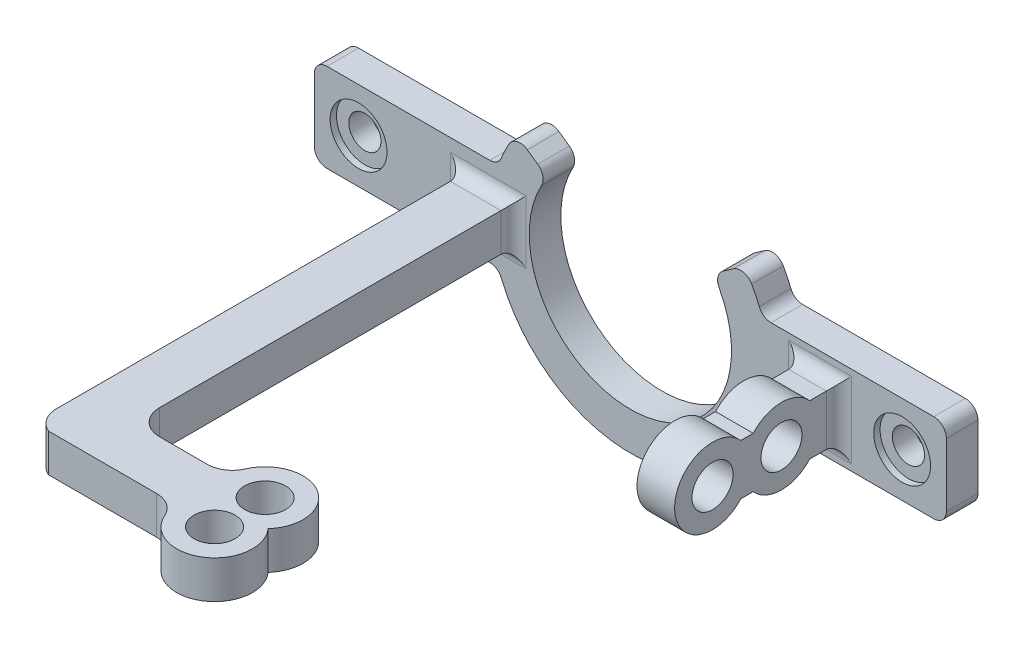
from build123d import *

# Parameters (mm, degrees)
SKETCH1_R                = 2.55
BOSS_EXTRUDE1_DEPTH      = 5
SKETCH4_R                = 4.5
CUT_EXTRUDE2_DEPTH       = 1
SKETCH6_W                = 5.947651005
SKETCH6_H                = 20
BOSS_EXTRUDE2_DEPTH      = 4
BOSS_EXTRUDE2_DEPTH_BACK = 4
SKETCH11_R               = 4.5
CUT_EXTRUDE3_DEPTH       = 0.5
SKETCH16_R               = 3.25
BOSS_EXTRUDE3_DEPTH      = 3
BOSS_EXTRUDE3_DEPTH_BACK = 3
FILLET3_R                = 2
BOSS_EXTRUDE4_DEPTH      = 5.947651
CUT_EXTRUDE5_REACH       = 85
SKETCH18_R               = 3.25


with BuildPart() as part:
    # Sketch1 → Boss-Extrude1 (new body)
    with BuildSketch(Plane.XY):
        with BuildLine():
            Line((100, 25), (100, 20))
            ThreePointArc((100, 20), (99.414213562, 18.585786438), (98, 18))
            Line((98, 18), (72.248595461, 18))
            ThreePointArc((72.248595461, 18), (71.130561473, 17.658312395), (70.39454584, 16.75))
            ThreePointArc((70.39454584, 16.75), (50, 3), (29.60545416, 16.75))
            ThreePointArc((29.60545416, 16.75), (28.869438527, 17.658312395), (27.751404539, 18))
            Line((27.751404539, 18), (2, 18))
            ThreePointArc((2, 18), (0.585786438, 18.585786438), (0, 20))
            Line((0, 20), (0, 25))
            Line((0, 25), (0, 30))
            ThreePointArc((0, 30), (0.585786438, 31.414213562), (2, 32))
            Line((2, 32), (21.056240945, 32))
            Line((21.056240945, 32), (27.751404539, 32))
            ThreePointArc((27.751404539, 32), (28.869438527, 32.341687605), (29.60545416, 33.25))
            ThreePointArc((29.60545416, 33.25), (30.166752838, 34.520625347), (30.807119991, 35.753295167))
            ThreePointArc((30.807119991, 35.753295167), (32.106461975, 36.725482012), (33.699080137, 36.414026968))
            Line((33.699080137, 36.414026968), (35.34656276, 35.260447216))
            ThreePointArc((35.34656276, 35.260447216), (36.146649881, 34.078494315), (35.955031011, 32.664127224))
            ThreePointArc((35.955031011, 32.664127224), (50, 9), (64.044968989, 32.664127224))
            ThreePointArc((64.044968989, 32.664127224), (63.853350119, 34.078494315), (64.65343724, 35.260447216))
            Line((64.65343724, 35.260447216), (66.300919863, 36.414026968))
            ThreePointArc((66.300919863, 36.414026968), (67.893538025, 36.725482012), (69.192880009, 35.753295167))
            ThreePointArc((69.192880009, 35.753295167), (69.833247162, 34.520625347), (70.39454584, 33.25))
            ThreePointArc((70.39454584, 33.25), (71.130561473, 32.341687605), (72.248595461, 32))
            Line((72.248595461, 32), (78.943759055, 32))
            Line((78.943759055, 32), (98, 32))
            ThreePointArc((98, 32), (99.414213562, 31.414213562), (100, 30))
            Line((100, 30), (100, 25))
        make_face()
        with Locations((93, 25)):
            Circle(SKETCH1_R, mode=Mode.SUBTRACT)
        with Locations((7, 25)):
            Circle(SKETCH1_R, mode=Mode.SUBTRACT)
    extrude(amount=BOSS_EXTRUDE1_DEPTH)

    # Sketch4 → Cut-Extrude2 (cut)
    with BuildSketch(Plane.XY.offset(5)):
        with Locations((93, 25)):
            Circle(SKETCH4_R)
        with Locations((7, 25)):
            Circle(SKETCH4_R)
    extrude(amount=-CUT_EXTRUDE2_DEPTH, mode=Mode.SUBTRACT)

    # Sketch6 → Boss-Extrude2 (add, two sides)
    with BuildSketch(Plane(origin=(0, 25, 0), x_dir=(-1, 0, 0), z_dir=(0, -1, 0))) as boss_extrude2_sk:
        with Locations((-80.026174497, -15)):
            Rectangle(SKETCH6_W, SKETCH6_H)
    extrude(amount=BOSS_EXTRUDE2_DEPTH)
    extrude(boss_extrude2_sk.sketch, amount=-BOSS_EXTRUDE2_DEPTH_BACK)

    # Sketch11 → Cut-Extrude3 (cut)
    with BuildSketch(Plane(origin=(0, 0, 0), x_dir=(-1, 0, 0), z_dir=(0, 0, -1))):
        with Locations((-93, 25)):
            Circle(SKETCH11_R)
        with Locations((-7, 25)):
            Circle(SKETCH11_R)
    extrude(amount=-CUT_EXTRUDE3_DEPTH, mode=Mode.SUBTRACT)

    # Sketch16 → Boss-Extrude3 (add, two sides)
    with BuildSketch(Plane(origin=(0, 25, 0), x_dir=(-1, 0, 0), z_dir=(0, -1, 0))) as boss_extrude3_sk:
        with BuildLine():
            Line((-31.525983958, -5), (-31.525983958, -48.851508305))
            Line((-31.525983958, -48.851508305), (-31.525983958, -61))
            ThreePointArc((-31.525983958, -61), (-32.697556833, -63.828427125), (-35.525983958, -65))
            Line((-35.525983958, -65), (-43.054928699, -65))
            ThreePointArc((-43.054928699, -65), (-45.245818929, -64.346640106), (-46.720989255, -62.6))
            ThreePointArc((-46.720989255, -62.6), (-55.461014998, -59.950609847), (-56.692216044, -69))
            ThreePointArc((-56.692216044, -69), (-55.461014998, -78.049390153), (-46.720989255, -75.4))
            ThreePointArc((-46.720989255, -75.4), (-45.245818929, -73.653359894), (-43.054928699, -73))
            Line((-43.054928699, -73), (-25.956550891, -73))
            ThreePointArc((-25.956550891, -73), (-24.188489968, -71.525548017), (-23.525983958, -69.320750097))
            Line((-23.525983958, -69.320750097), (-23.525983958, -5))
            Line((-23.525983958, -5), (-31.525983958, -5))
        make_face()
        with Locations((-52.220080089, -73)):
            Circle(SKETCH16_R, mode=Mode.SUBTRACT)
        with Locations((-52.220080089, -65)):
            Circle(SKETCH16_R, mode=Mode.SUBTRACT)
    extrude(amount=BOSS_EXTRUDE3_DEPTH)
    extrude(boss_extrude3_sk.sketch, amount=-BOSS_EXTRUDE3_DEPTH_BACK)

    # Fillet3
    fillet3_edges = [part.edges().sort_by_distance(p)[0] for p in [
        (83, 25, 5),
        (80.026174498, 29, 5),
        (77.052348995, 25, 5),
        (80.026174498, 21, 5),
        (31.525983958, 25, 5),
        (27.525983958, 28, 5),
        (23.525983958, 25, 5),
        (27.525983958, 22, 5),
    ]]
    fillet(fillet3_edges, radius=FILLET3_R)

    # Sketch17 → Boss-Extrude4 (add)
    with BuildSketch(Plane(origin=(83, 0, 0), x_dir=(0, 0, -1), z_dir=(1, 0, 0))):
        with BuildLine():
            ThreePointArc((-19.547210182, 27.503414308), (-31, 25), (-19.547210182, 22.496585692))
            ThreePointArc((-19.547210182, 22.496585692), (-8.094420363, 25), (-19.547210182, 27.503414308))
        make_face()
    extrude(amount=-BOSS_EXTRUDE4_DEPTH)

    # Sketch18 → Cut-Extrude5 (cut, up to next)
    with BuildSketch(Plane(origin=(83, 0, 0), x_dir=(0, 0, -1), z_dir=(1, 0, 0)), mode=Mode.PRIVATE) as cut_extrude5_sk1:
        with Locations((-25, 25)):
            Circle(SKETCH18_R)
    cut_extrude5_tool1 = extrude(cut_extrude5_sk1.sketch, amount=-CUT_EXTRUDE5_REACH, mode=Mode.PRIVATE) & part.part
    add(cut_extrude5_tool1.solids().sort_by_distance((83, 25, 25))[0], mode=Mode.SUBTRACT)
    # Sketch18 → Cut-Extrude5 (cut, up to next)
    with BuildSketch(Plane(origin=(83, 0, 0), x_dir=(0, 0, -1), z_dir=(1, 0, 0)), mode=Mode.PRIVATE) as cut_extrude5_sk2:
        with Locations((-14.094420363, 25)):
            Circle(SKETCH18_R)
    cut_extrude5_tool2 = extrude(cut_extrude5_sk2.sketch, amount=-CUT_EXTRUDE5_REACH, mode=Mode.PRIVATE) & part.part
    add(cut_extrude5_tool2.solids().sort_by_distance((83, 25, 14.09442))[0], mode=Mode.SUBTRACT)


solid = part.part
